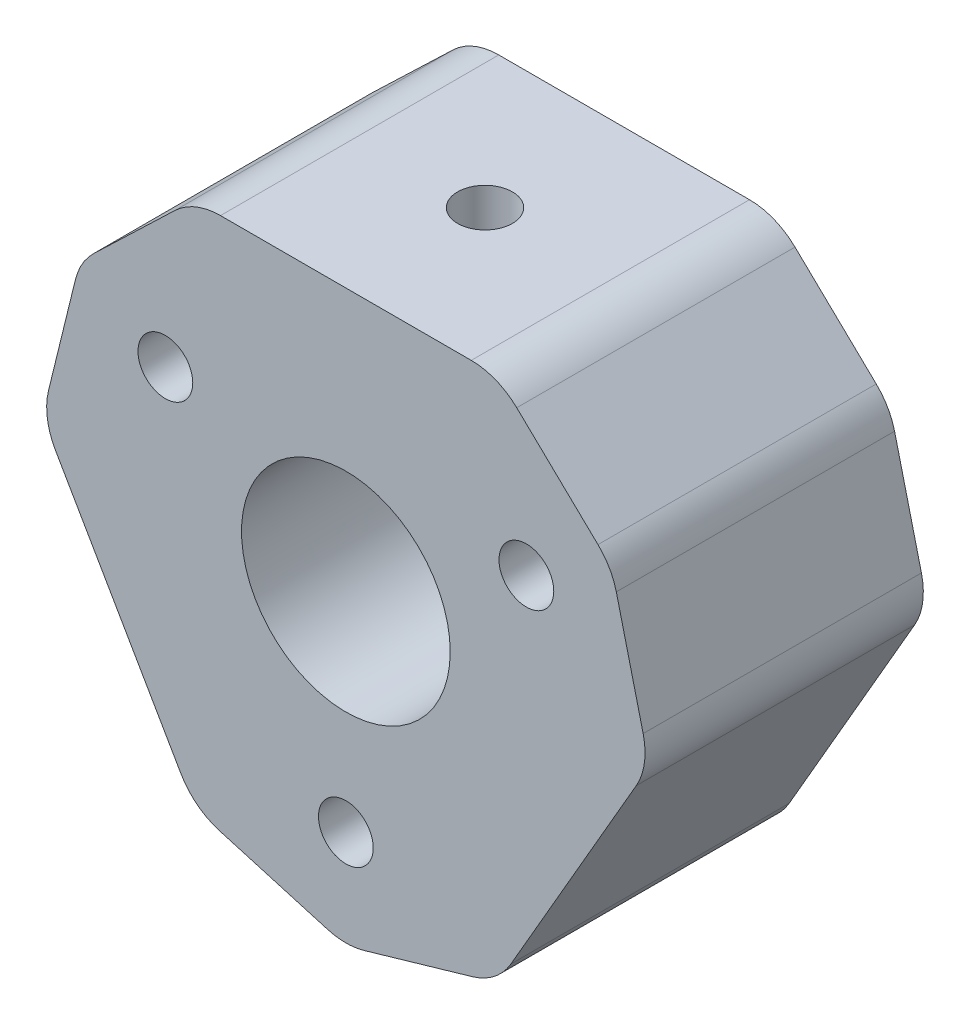
from build123d import *

# Parameters (mm, degrees)
SKETCH1_R           = 4.7625
SKETCH1_R_2         = 1.25
BOSS_EXTRUDE1_DEPTH = 12.7
CUT_EXTRUDE1_REACH  = 27.888
SKETCH2_R           = 1.25


with BuildPart() as part:
    # Sketch1 → Boss-Extrude1 (new body)
    with BuildSketch(Plane.XY):
        with BuildLine():
            Line((-13.253372163, -1.044486042), (-7.531237528, -10.955513958))
            ThreePointArc((-7.531237528, -10.955513958), (-6.784217233, -11.816359568), (-5.770008435, -12.336431676))
            Line((-5.770008435, -12.336431676), (-0.836847118, -13.76941319))
            ThreePointArc((-0.836847118, -13.76941319), (0, -13.888495471), (0.836847118, -13.76941319))
            Line((0.836847118, -13.76941319), (5.770008435, -12.336431676))
            ThreePointArc((5.770008435, -12.336431676), (6.784217233, -11.816359568), (7.531237528, -10.955513958))
            Line((7.531237528, -10.955513958), (13.253372163, -1.044486042))
            ThreePointArc((13.253372163, -1.044486042), (13.625376182, 0.032875315), (13.568667441, 1.171241953))
            Line((13.568667441, 1.171241953), (12.343085176, 6.159975731))
            ThreePointArc((12.343085176, 6.159975731), (12.027789898, 6.944247736), (11.506238058, 7.609437458))
            Line((11.506238058, 7.609437458), (7.798659006, 11.165189723))
            ThreePointArc((7.798659006, 11.165189723), (6.841158949, 11.783484253), (5.722134635, 12))
            Line((5.722134635, 12), (-5.722134635, 12))
            ThreePointArc((-5.722134635, 12), (-6.841158949, 11.783484253), (-7.798659006, 11.165189723))
            Line((-7.798659006, 11.165189723), (-11.506238058, 7.609437458))
            ThreePointArc((-11.506238058, 7.609437458), (-12.027789898, 6.944247736), (-12.343085176, 6.159975731))
            Line((-12.343085176, 6.159975731), (-13.568667441, 1.171241953))
            ThreePointArc((-13.568667441, 1.171241953), (-13.625376182, 0.032875315), (-13.253372163, -1.044486042))
        make_face()
        Circle(SKETCH1_R, mode=Mode.SUBTRACT)
        with Locations((-8.238066653, 4.75625)):
            Circle(SKETCH1_R_2, mode=Mode.SUBTRACT)
        with Locations((8.238066653, 4.75625)):
            Circle(SKETCH1_R_2, mode=Mode.SUBTRACT)
        with Locations((0, -9.5125)):
            Circle(SKETCH1_R_2, mode=Mode.SUBTRACT)
    extrude(amount=BOSS_EXTRUDE1_DEPTH)

    # Sketch2 → Cut-Extrude1 (cut, up to next)
    with BuildSketch(Plane(origin=(0, 12, 0), x_dir=(1, 0, 0), z_dir=(0, 1, 0)), mode=Mode.PRIVATE) as cut_extrude1_sk1:
        with Locations((0, -6.35)):
            Circle(SKETCH2_R)
    cut_extrude1_tool1 = extrude(cut_extrude1_sk1.sketch, amount=-CUT_EXTRUDE1_REACH, mode=Mode.PRIVATE) & part.part
    add(cut_extrude1_tool1.solids().sort_by_distance((0, 12, 6.35))[0], mode=Mode.SUBTRACT)


solid = part.part
